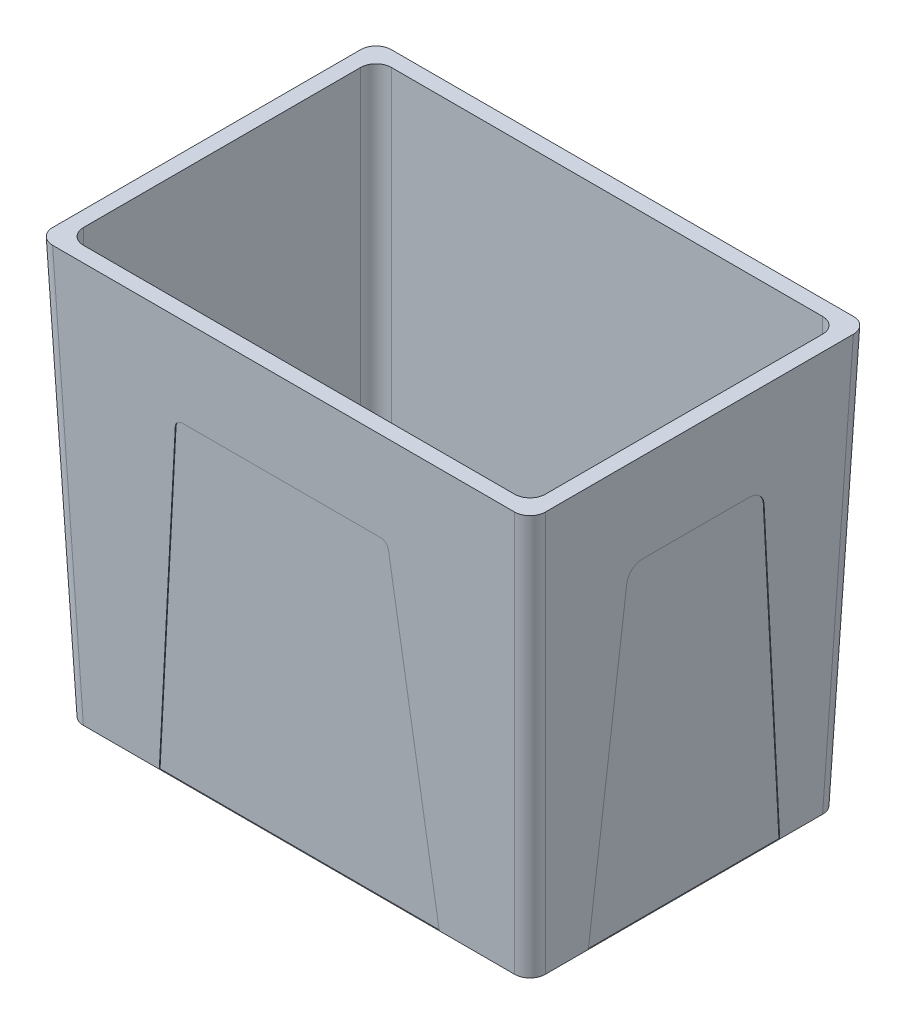
from build123d import *

# Parameters (mm, degrees)
SKETCH1_W          = 300
SKETCH1_H          = 200
SKETCH2_W          = 320
SKETCH2_H          = 220
FILLET1_R          = 10
CUT_EXTRUDE1_DEPTH = 250
CUT_EXTRUDE3_DEPTH = 0.5
CUT_EXTRUDE4_DEPTH = 0.5


with BuildPart() as part:
    # Sketch1 → Loft1 section 0
    with BuildSketch(Plane(origin=(0, 0, 0), x_dir=(1, 0, 0), z_dir=(0, 1, 0))):
        Rectangle(SKETCH1_W, SKETCH1_H)
    # Sketch2 → Loft1 section 1
    with BuildSketch(Plane(origin=(0, 270, 0), x_dir=(1, 0, 0), z_dir=(0, 1, 0))):
        Rectangle(SKETCH2_W, SKETCH2_H)
    loft()

    # Fillet1
    fillet1_edges = [part.edges().sort_by_distance(p)[0] for p in [
        (155, 135, -105),
        (155, 135, 105),
        (-155, 135, 105),
        (-155, 135, -105),
    ]]
    fillet(fillet1_edges, radius=FILLET1_R)

    # Sketch3 → Cut-Extrude1 (cut)
    with BuildSketch(Plane(origin=(0, 270, 0), x_dir=(1, 0, 0), z_dir=(0, 1, 0))):
        with BuildLine():
            Line((-140, 100), (140, 100))
            ThreePointArc((140, 100), (147.071067812, 97.071067812), (150, 90))
            Line((150, 90), (150, -90))
            ThreePointArc((150, -90), (147.071067812, -97.071067812), (140, -100))
            Line((140, -100), (-140, -100))
            ThreePointArc((-140, -100), (-147.071067812, -97.071067812), (-150, -90))
            Line((-150, -90), (-150, 90))
            ThreePointArc((-150, 90), (-147.071067812, 97.071067812), (-140, 100))
        make_face()
    extrude(amount=-CUT_EXTRUDE1_DEPTH, mode=Mode.SUBTRACT)

    # Sketch4 → Cut-Extrude3 (cut)
    with BuildSketch(Plane(origin=(0, -3.698630137, 99.863013699), x_dir=(1, 0, 0), z_dir=(0, -0.037011661, 0.999314834))):
        with BuildLine():
            Line((-90.72593498, 3.701166051), (-72.75263326, 209.136944765))
            ThreePointArc((-72.75263326, 209.136944765), (-71.149610808, 212.387552735), (-67.77165977, 213.701166051))
            Line((-67.77165977, 213.701166051), (60.703357415, 213.701166051))
            ThreePointArc((60.703357415, 213.701166051), (64.015057291, 212.447183126), (65.665631129, 209.314223623))
            Line((65.665631129, 209.314223623), (90.668274157, 6.935256238))
            Line((90.668274157, 6.935256238), (91.067825571, 3.701166051))
            Line((91.067825571, 3.701166051), (-90.72593498, 3.701166051))
        make_face()
    cut_extrude3 = extrude(amount=-CUT_EXTRUDE3_DEPTH, mode=Mode.SUBTRACT)

    # Mirror1: Cut-Extrude3 across plane
    add(cut_extrude3.mirror(Plane.XY), mode=Mode.SUBTRACT)

    # Sketch5 → Cut-Extrude4 (cut)
    with BuildSketch(Plane(origin=(149.794520548, -5.547945205, 0), x_dir=(0, 0, -1), z_dir=(0.999314834, -0.037011661, 0))):
        with BuildLine():
            Line((-62.157161102, 5.551749076), (-44.583177002, 206.423306504))
            ThreePointArc((-44.583177002, 206.423306504), (-41.377132097, 212.924522445), (-34.621230021, 215.551749076))
            Line((-34.621230021, 215.551749076), (34.621230021, 215.551749076))
            ThreePointArc((34.621230021, 215.551749076), (41.377132097, 212.924522445), (44.583177002, 206.423306504))
            Line((44.583177002, 206.423306504), (62.157161102, 5.551749076))
            Line((62.157161102, 5.551749076), (-62.157161102, 5.551749076))
        make_face()
    cut_extrude4 = extrude(amount=-CUT_EXTRUDE4_DEPTH, mode=Mode.SUBTRACT)

    # Mirror2: Cut-Extrude4 across plane
    add(cut_extrude4.mirror(Plane(origin=(0, 0, 0), x_dir=(0, 0, 1), z_dir=(1, 0, 0))), mode=Mode.SUBTRACT)


solid = part.part
